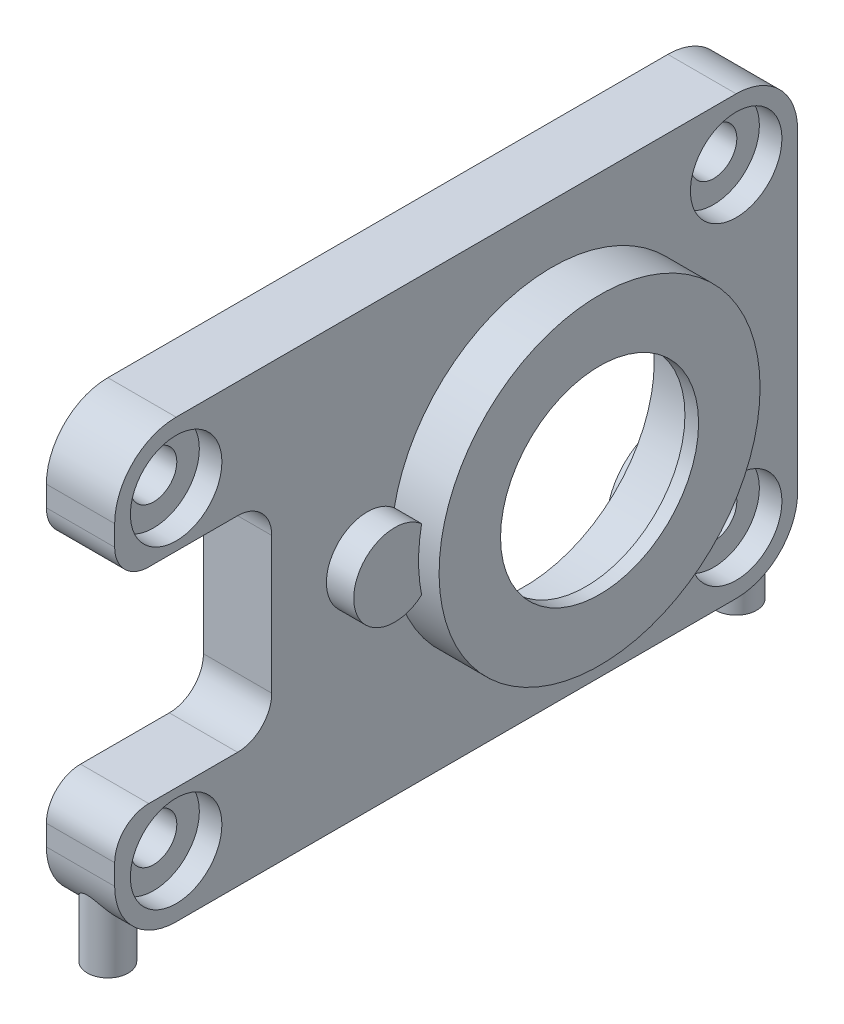
from build123d import *

# Parameters (mm, degrees)
SKETCH1_R                       = 7.25
BOSS_EXTRUDE1_DEPTH             = 5
SKETCH2_R                       = 11.75
SKETCH2_R_2                     = 7.25
BOSS_EXTRUDE2_DEPTH             = 3.5
FILLET1_R                       = 4.5
FILLET2_R                       = 2.5
SKETCH3_R                       = 1.5
BOSS_EXTRUDE3_DEPTH             = 2.5
BOSS_EXTRUDE3_DIRECTION_2_REACH = 34
CBORE_FOR_M3_SBHCS1_D           = 3.4
CBORE_FOR_M3_SBHCS1_CBORE_D     = 6.7
CBORE_FOR_M3_SBHCS1_CBORE_DEPTH = 1.65
SKETCH6_R                       = 7.25
CUT_EXTRUDE1_DEPTH              = 3
SKETCH7_R                       = 9.5
CUT_EXTRUDE2_DEPTH              = 4.5
SKETCH10_R                      = 3
BOSS_EXTRUDE5_DEPTH             = 2
SKETCH11_R                      = 3
BOSS_EXTRUDE6_DEPTH             = 0.5
SKETCH12_R                      = 1.5
CUT_EXTRUDE4_DEPTH              = 4


with BuildPart() as part:
    # Sketch1 → Boss-Extrude1 (new body)
    with BuildSketch(Plane(origin=(0, 0, 0), x_dir=(0, 0, -1), z_dir=(1, 0, 0))):
        Polygon((-25, 16), (-25, 7.5), (-13.5, 7.5), (-13.5, -7.5), (-25, -7.5), (-25, -16), (25, -16), (25, 16), align=None)
        with Locations((7, 0)):
            Circle(SKETCH1_R, mode=Mode.SUBTRACT)
    extrude(amount=BOSS_EXTRUDE1_DEPTH)

    # Sketch2 → Boss-Extrude2 (add)
    with BuildSketch(Plane(origin=(5, 0, 0), x_dir=(0, 0, -1), z_dir=(1, 0, 0))):
        with Locations((7, 0)):
            Circle(SKETCH2_R)
        with Locations((7, 0)):
            Circle(SKETCH2_R_2, mode=Mode.SUBTRACT)
    extrude(amount=BOSS_EXTRUDE2_DEPTH)

    # Fillet1
    fillet1_edges = [part.edges().sort_by_distance(p)[0] for p in [
        (2.5, 16, 25),
        (2.5, 16, -25),
        (2.5, -16, -25),
        (2.5, -16, 25),
    ]]
    fillet(fillet1_edges, radius=FILLET1_R)

    # Fillet2
    fillet2_edges = [part.edges().sort_by_distance(p)[0] for p in [
        (2.5, 7.5, 13.5),
        (2.5, 7.5, 25),
        (2.5, -7.5, 25),
        (2.5, -7.5, 13.5),
    ]]
    fillet(fillet2_edges, radius=FILLET2_R)

    # Sketch3 → Boss-Extrude3 (add)
    with BuildSketch(Plane(origin=(0, -16, 0), x_dir=(-1, 0, 0), z_dir=(0, -1, 0))):
        with Locations((-2.5, -23)):
            Circle(SKETCH3_R)
        with Locations((-2.5, 23)):
            Circle(SKETCH3_R)
    extrude(amount=BOSS_EXTRUDE3_DEPTH)

    # Sketch3 → Boss-Extrude3 direction 2 (add, up to next)
    with BuildSketch(Plane(origin=(0, -16, 0), x_dir=(-1, 0, 0), z_dir=(0, -1, 0)), mode=Mode.PRIVATE) as boss_extrude3_direction_2_sk1:
        with Locations((-2.5, -23)):
            Circle(SKETCH3_R)
    boss_extrude3_direction_2_tool1 = extrude(boss_extrude3_direction_2_sk1.sketch, amount=-BOSS_EXTRUDE3_DIRECTION_2_REACH, mode=Mode.PRIVATE) - part.part
    add(boss_extrude3_direction_2_tool1.solids().sort_by_distance((2.5, -16, 23))[0])
    # Sketch3 → Boss-Extrude3 direction 2 (add, up to next)
    with BuildSketch(Plane(origin=(0, -16, 0), x_dir=(-1, 0, 0), z_dir=(0, -1, 0)), mode=Mode.PRIVATE) as boss_extrude3_direction_2_sk2:
        with Locations((-2.5, 23)):
            Circle(SKETCH3_R)
    boss_extrude3_direction_2_tool2 = extrude(boss_extrude3_direction_2_sk2.sketch, amount=-BOSS_EXTRUDE3_DIRECTION_2_REACH, mode=Mode.PRIVATE) - part.part
    add(boss_extrude3_direction_2_tool2.solids().sort_by_distance((2.5, -16, -23))[0])

    # CBORE for M3 SBHCS1 (through all)
    with Locations(Plane(origin=(5, 0, 0), x_dir=(0, 0, -1), z_dir=(1, 0, 0))):
        with Locations((-20.5, 11.5), (-20.5, -11.5), (20.5, 11.5), (20.5, -11.5)):
            CounterBoreHole(CBORE_FOR_M3_SBHCS1_D / 2, CBORE_FOR_M3_SBHCS1_CBORE_D / 2, CBORE_FOR_M3_SBHCS1_CBORE_DEPTH)

    # Sketch6 → Cut-Extrude1 (cut)
    with BuildSketch(Plane.ZY):
        with BuildLine():
            Line((11.5, 5), (11.5, 14))
            Line((11.5, 14), (-16.758342613, 14))
            ThreePointArc((-16.758342613, 14), (-16.19375696, 12.80624304), (-16, 11.5))
            ThreePointArc((-16, 11.5), (-18.378679656, 7.531373033), (-23, 7.758342613))
            Line((-23, 7.758342613), (-23, -7.758342613))
            ThreePointArc((-23, -7.758342613), (-18.378679656, -7.531373033), (-16, -11.5))
            ThreePointArc((-16, -11.5), (-16.19375696, -12.80624304), (-16.758342613, -14))
            Line((-16.758342613, -14), (11.5, -14))
            Line((11.5, -14), (11.5, -5))
            Line((11.5, -5), (11.5, 5))
        make_face()
        with Locations((-7, 0)):
            Circle(SKETCH6_R, mode=Mode.SUBTRACT)
    extrude(amount=-CUT_EXTRUDE1_DEPTH, mode=Mode.SUBTRACT)

    # Sketch7 → Cut-Extrude2 (cut)
    with BuildSketch(Plane.ZY.offset(-3)):
        with Locations((-7, 0)):
            Circle(SKETCH7_R)
    extrude(amount=-CUT_EXTRUDE2_DEPTH, mode=Mode.SUBTRACT)

    # Sketch10 → Boss-Extrude5 (add)
    with BuildSketch(Plane(origin=(5, 0, 0), x_dir=(0, 0, -1), z_dir=(1, 0, 0))):
        with Locations((-6.5, 0)):
            Circle(SKETCH10_R)
    extrude(amount=BOSS_EXTRUDE5_DEPTH)

    # Sketch11 → Boss-Extrude6 (add)
    with BuildSketch(Plane.ZY.offset(-3)):
        with Locations((6.5, 0)):
            Circle(SKETCH11_R)
    extrude(amount=BOSS_EXTRUDE6_DEPTH)

    # Sketch12 → Cut-Extrude4 (cut)
    with BuildSketch(Plane.ZY.offset(-2.5)):
        with Locations((6.5, 0)):
            Circle(SKETCH12_R)
    extrude(amount=-CUT_EXTRUDE4_DEPTH, mode=Mode.SUBTRACT)


solid = part.part
